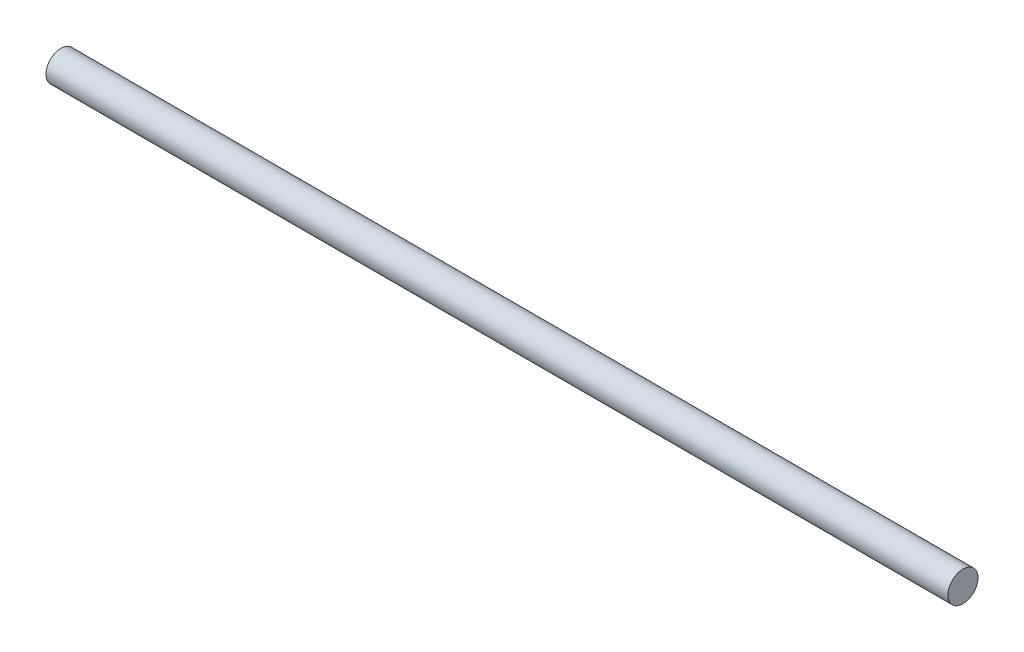
from build123d import *

# Parameters (mm, degrees)
BOSS_EXTRUDE1_DEPTH      = 30
BOSS_EXTRUDE1_DEPTH_BACK = 30
SKETCH1_R                = 1


with BuildPart() as part:
    # Sketch1 → Boss-Extrude1 (new, two sides: drawn at the far end of the back side and taken through both)
    with BuildSketch(Plane(origin=(0, 0, 0), x_dir=(0, 0, -1), z_dir=(1, 0, 0)).offset(-BOSS_EXTRUDE1_DEPTH_BACK)):
        Circle(SKETCH1_R)
    extrude(amount=BOSS_EXTRUDE1_DEPTH + BOSS_EXTRUDE1_DEPTH_BACK)


solid = part.part
